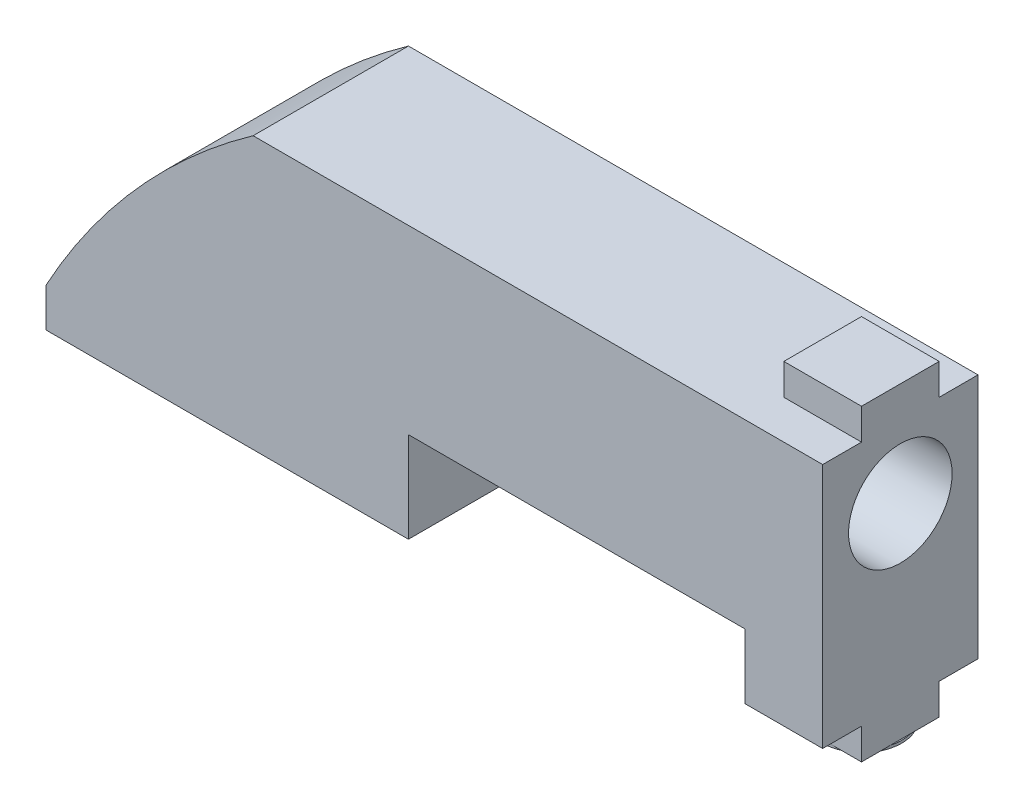
from build123d import *

# Parameters (mm, degrees)
EXTRUSION1_DEPTH                  = 3
ESQUISSE2_W                       = 3
ESQUISSE2_H                       = 3
EXTRUSION2_DEPTH                  = 1.2
ESQUISSE3_W                       = 3
ESQUISSE3_H                       = 3
EXTRUSION3_DEPTH                  = 1.2
DIAM_TRE_DU_PER_AGE_4_0_4_1_D     = 4
DIAM_TRE_DU_PER_AGE_4_0_4_1_DEPTH = 3
DIAM_TRE_DU_PER_AGE_4_0_4_1_TIP   = 1.201721238
ESQUISSE6_R                       = 1.525615423
EXTRUSION4_DEPTH                  = 0.1


with BuildPart() as part:
    # Esquisse1 → Extrusion1 (new body, symmetric)
    with BuildSketch(Plane.XY):
        with BuildLine():
            Line((0, 0), (0, 1.5))
            ThreePointArc((0, 1.5), (3.484063784, 6.45860997), (8, 10.5))
            Line((8, 10.5), (30, 10.5))
            Line((30, 10.5), (30, 1))
            Line((30, 1), (27, 1))
            Line((27, 1), (27, 3.5))
            Line((27, 3.5), (14, 3.5))
            Line((14, 3.5), (14, 0))
            Line((14, 0), (0, 0))
        make_face()
    extrude(amount=EXTRUSION1_DEPTH, both=True)

    # Esquisse2 → Extrusion2 (add)
    with BuildSketch(Plane(origin=(0, 10.5, 0), x_dir=(1, 0, 0), z_dir=(0, 1, 0))):
        with Locations((28.5, 0)):
            Rectangle(ESQUISSE2_W, ESQUISSE2_H)
    extrude(amount=EXTRUSION2_DEPTH)

    # Esquisse3 → Extrusion3 (add)
    with BuildSketch(Plane.XZ.offset(-1)):
        with Locations((28.5, 0)):
            Rectangle(ESQUISSE3_W, ESQUISSE3_H)
    extrude(amount=EXTRUSION3_DEPTH)

    # Diamètre du perçage Ø4.0 (4)1
    with Locations(Plane(origin=(30, 0, 0), x_dir=(0, 0, -1), z_dir=(1, 0, 0))):
        with Locations((0, 7.7)):
            Hole(DIAM_TRE_DU_PER_AGE_4_0_4_1_D / 2, depth=DIAM_TRE_DU_PER_AGE_4_0_4_1_DEPTH)
            with Locations((0, 0, -(DIAM_TRE_DU_PER_AGE_4_0_4_1_DEPTH + DIAM_TRE_DU_PER_AGE_4_0_4_1_TIP / 2))):  # 118° drill point
                Cone(0, DIAM_TRE_DU_PER_AGE_4_0_4_1_D / 2, DIAM_TRE_DU_PER_AGE_4_0_4_1_TIP, mode=Mode.SUBTRACT)

    # Esquisse6 → Extrusion4 (add)
    with BuildSketch(Plane.XZ.offset(0.2)):
        with Locations((28.525615423, 0)):
            Circle(ESQUISSE6_R)
    extrude(amount=EXTRUSION4_DEPTH)


solid = part.part
